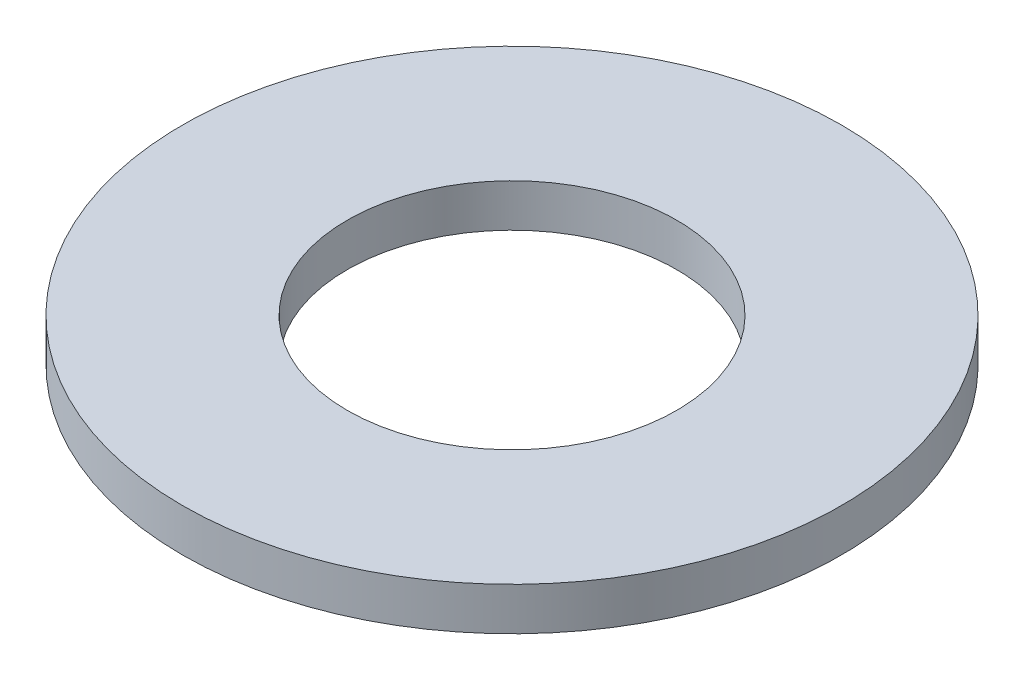
from build123d import *

# Parameters (mm, degrees)
SKETCH1_R           = 12.7
SKETCH1_R_2         = 6.35
BOSS_EXTRUDE1_DEPTH = 1.651


with BuildPart() as part:
    # Sketch1 → Boss-Extrude1 (new body)
    with BuildSketch(Plane(origin=(0, 0, 0), x_dir=(1, 0, 0), z_dir=(0, 1, 0))):
        Circle(SKETCH1_R)
        Circle(SKETCH1_R_2, mode=Mode.SUBTRACT)
    extrude(amount=BOSS_EXTRUDE1_DEPTH)


solid = part.part
